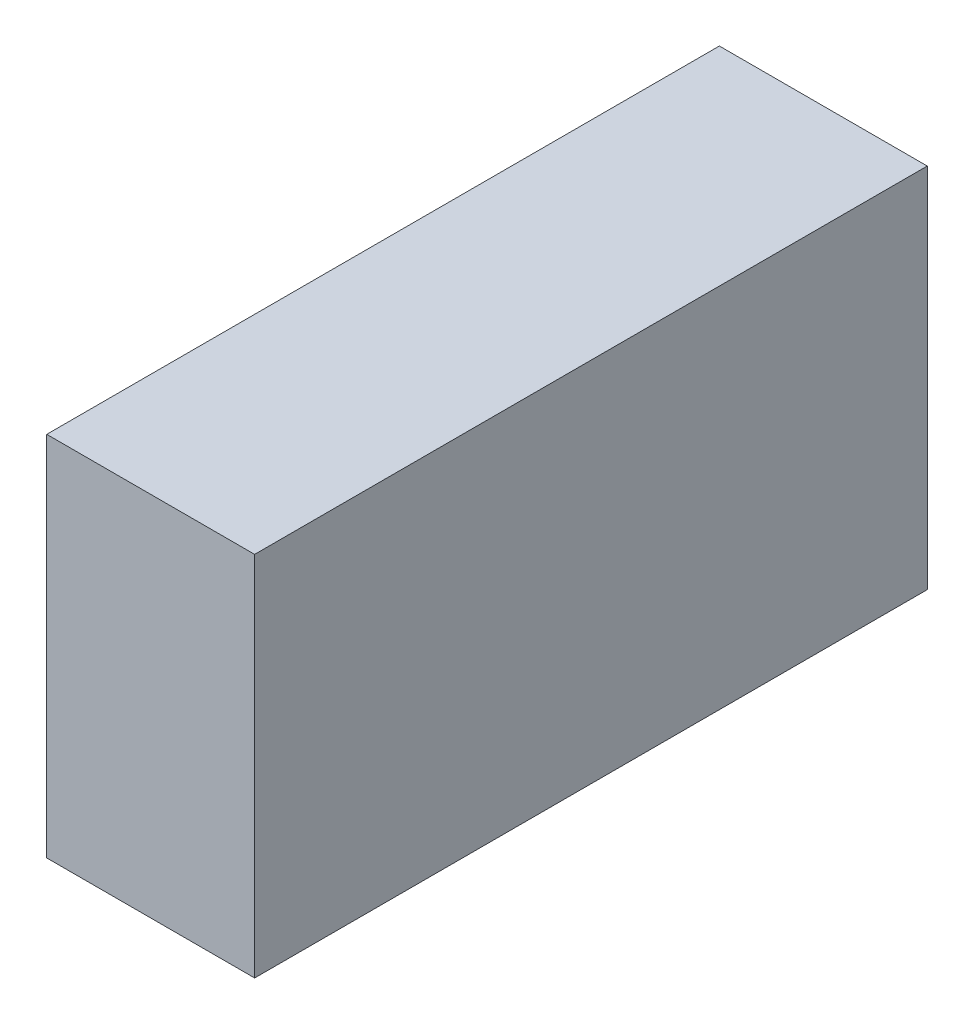
from build123d import *

# Parameters (mm, degrees)
ESQUISSE1_W        = 17
ESQUISSE1_H        = 55
BOSS_EXTRU_1_DEPTH = 30


with BuildPart() as part:
    # Esquisse1 → Boss.-Extru.1 (new body)
    with BuildSketch(Plane(origin=(0, -86.357994307, 0), x_dir=(1, 0, 0), z_dir=(0, 1, 0))):
        with Locations((-43.705845974, -35.345639742)):
            Rectangle(ESQUISSE1_W, ESQUISSE1_H)
    extrude(amount=BOSS_EXTRU_1_DEPTH)


solid = part.part
